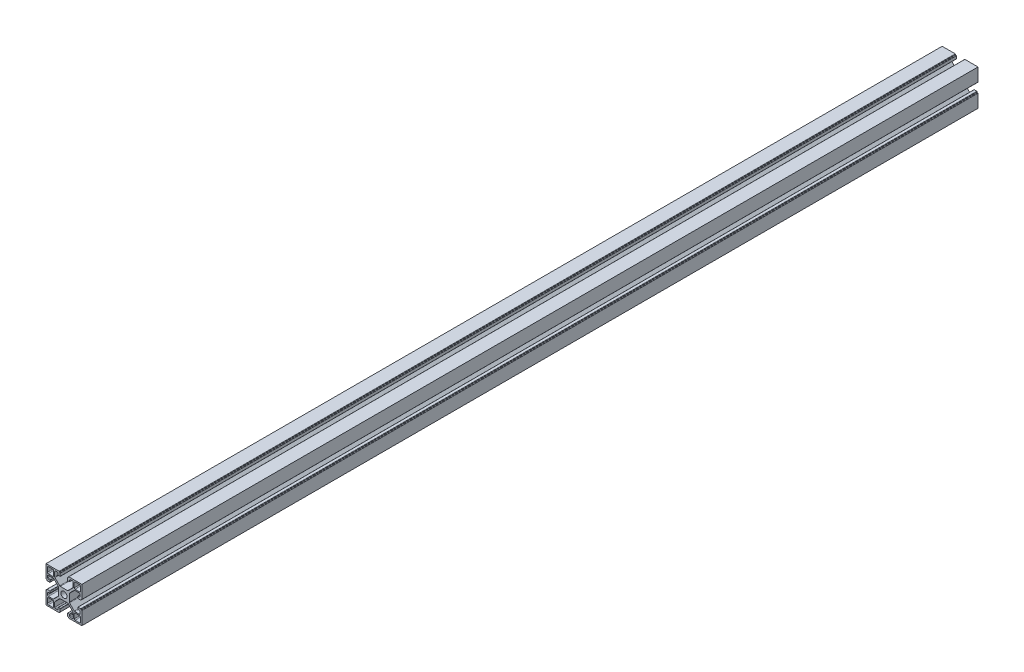
from build123d import *

# Parameters (mm, degrees)
SKETCH_1_R      = 3.4
EXTRUDE_1_DEPTH = 1000


with BuildPart() as part:
    # Эскиз1 → Бобышка-Вытянуть1 (new body)
    with BuildSketch(Plane.XY):
        with BuildLine():
            Line((-20, 20), (-20, 10.25))
            Line((-20, 10.25), (-20, 5.4))
            ThreePointArc((-20, 5.4), (-19.912132034, 5.187867966), (-19.7, 5.1))
            Line((-19.7, 5.1), (-19.3, 5.1))
            ThreePointArc((-19.3, 5.1), (-19.087867966, 5.012132034), (-19, 4.8))
            Line((-19, 4.8), (-19, 4.4))
            ThreePointArc((-19, 4.4), (-18.912132034, 4.187867966), (-18.7, 4.1))
            Line((-18.7, 4.1), (-15.8, 4.1))
            ThreePointArc((-15.8, 4.1), (-15.587867966, 4.187867966), (-15.5, 4.4))
            Line((-15.5, 4.4), (-15.5, 6.1))
            ThreePointArc((-15.5, 6.1), (-15.587867966, 6.312132034), (-15.8, 6.4))
            Line((-15.8, 6.4), (-17.2, 6.4))
            ThreePointArc((-17.2, 6.4), (-17.907106781, 6.692893219), (-18.2, 7.4))
            Line((-18.2, 7.4), (-18.2, 9.25))
            ThreePointArc((-18.2, 9.25), (-17.907106781, 9.957106781), (-17.2, 10.25))
            Line((-17.2, 10.25), (-12.164213562, 10.25))
            ThreePointArc((-12.164213562, 10.25), (-11.78153013, 10.173879533), (-11.457106781, 9.957106781))
            Line((-11.457106781, 9.957106781), (-6.292893219, 4.792893219))
            ThreePointArc((-6.292893219, 4.792893219), (-6.076120467, 4.46846987), (-6, 4.085786438))
            Line((-6, 4.085786438), (-6, -4.085786438))
            ThreePointArc((-6, -4.085786438), (-6.076120467, -4.46846987), (-6.292893219, -4.792893219))
            Line((-6.292893219, -4.792893219), (-11.457106781, -9.957106781))
            ThreePointArc((-11.457106781, -9.957106781), (-11.78153013, -10.173879533), (-12.164213562, -10.25))
            Line((-12.164213562, -10.25), (-17.2, -10.25))
            ThreePointArc((-17.2, -10.25), (-17.907106781, -9.957106781), (-18.2, -9.25))
            Line((-18.2, -9.25), (-18.2, -7.4))
            ThreePointArc((-18.2, -7.4), (-17.907106781, -6.692893219), (-17.2, -6.4))
            Line((-17.2, -6.4), (-15.8, -6.4))
            ThreePointArc((-15.8, -6.4), (-15.587867966, -6.312132034), (-15.5, -6.1))
            Line((-15.5, -6.1), (-15.5, -4.4))
            ThreePointArc((-15.5, -4.4), (-15.587867966, -4.187867966), (-15.8, -4.1))
            Line((-15.8, -4.1), (-18.7, -4.1))
            ThreePointArc((-18.7, -4.1), (-18.912132034, -4.187867966), (-19, -4.4))
            Line((-19, -4.4), (-19, -4.8))
            ThreePointArc((-19, -4.8), (-19.087867966, -5.012132034), (-19.3, -5.1))
            Line((-19.3, -5.1), (-19.7, -5.1))
            ThreePointArc((-19.7, -5.1), (-19.912132034, -5.187867966), (-20, -5.4))
            Line((-20, -5.4), (-20, -10.25))
            Line((-20, -10.25), (-20, -20))
            Line((-20, -20), (-10.25, -20))
            Line((-10.25, -20), (-5.4, -20))
            ThreePointArc((-5.4, -20), (-5.187867966, -19.912132034), (-5.1, -19.7))
            Line((-5.1, -19.7), (-5.1, -19.3))
            ThreePointArc((-5.1, -19.3), (-5.012132034, -19.087867966), (-4.8, -19))
            Line((-4.8, -19), (-4.4, -19))
            ThreePointArc((-4.4, -19), (-4.187867966, -18.912132034), (-4.1, -18.7))
            Line((-4.1, -18.7), (-4.1, -15.8))
            ThreePointArc((-4.1, -15.8), (-4.187867966, -15.587867966), (-4.4, -15.5))
            Line((-4.4, -15.5), (-6.1, -15.5))
            ThreePointArc((-6.1, -15.5), (-6.312132034, -15.587867966), (-6.4, -15.8))
            Line((-6.4, -15.8), (-6.4, -17.2))
            ThreePointArc((-6.4, -17.2), (-6.692893219, -17.907106781), (-7.4, -18.2))
            Line((-7.4, -18.2), (-9.25, -18.2))
            ThreePointArc((-9.25, -18.2), (-9.957106781, -17.907106781), (-10.25, -17.2))
            Line((-10.25, -17.2), (-10.25, -12.164213562))
            ThreePointArc((-10.25, -12.164213562), (-10.173879533, -11.78153013), (-9.957106781, -11.457106781))
            Line((-9.957106781, -11.457106781), (-4.792893219, -6.292893219))
            ThreePointArc((-4.792893219, -6.292893219), (-4.46846987, -6.076120467), (-4.085786438, -6))
            Line((-4.085786438, -6), (4.085786438, -6))
            ThreePointArc((4.085786438, -6), (4.46846987, -6.076120467), (4.792893219, -6.292893219))
            Line((4.792893219, -6.292893219), (9.957106781, -11.457106781))
            ThreePointArc((9.957106781, -11.457106781), (10.173879533, -11.78153013), (10.25, -12.164213562))
            Line((10.25, -12.164213562), (10.25, -17.2))
            ThreePointArc((10.25, -17.2), (9.957106781, -17.907106781), (9.25, -18.2))
            Line((9.25, -18.2), (7.4, -18.2))
            ThreePointArc((7.4, -18.2), (6.692893219, -17.907106781), (6.4, -17.2))
            Line((6.4, -17.2), (6.4, -15.8))
            ThreePointArc((6.4, -15.8), (6.312132034, -15.587867966), (6.1, -15.5))
            Line((6.1, -15.5), (4.4, -15.5))
            ThreePointArc((4.4, -15.5), (4.187867966, -15.587867966), (4.1, -15.8))
            Line((4.1, -15.8), (4.1, -18.7))
            ThreePointArc((4.1, -18.7), (4.187867966, -18.912132034), (4.4, -19))
            Line((4.4, -19), (4.8, -19))
            ThreePointArc((4.8, -19), (5.012132034, -19.087867966), (5.1, -19.3))
            Line((5.1, -19.3), (5.1, -19.7))
            ThreePointArc((5.1, -19.7), (5.187867966, -19.912132034), (5.4, -20))
            Line((5.4, -20), (10.25, -20))
            Line((10.25, -20), (20, -20))
            Line((20, -20), (20, -10.25))
            Line((20, -10.25), (20, -5.4))
            ThreePointArc((20, -5.4), (19.912132034, -5.187867966), (19.7, -5.1))
            Line((19.7, -5.1), (19.3, -5.1))
            ThreePointArc((19.3, -5.1), (19.087867966, -5.012132034), (19, -4.8))
            Line((19, -4.8), (19, -4.4))
            ThreePointArc((19, -4.4), (18.912132034, -4.187867966), (18.7, -4.1))
            Line((18.7, -4.1), (15.8, -4.1))
            ThreePointArc((15.8, -4.1), (15.587867966, -4.187867966), (15.5, -4.4))
            Line((15.5, -4.4), (15.5, -6.1))
            ThreePointArc((15.5, -6.1), (15.587867966, -6.312132034), (15.8, -6.4))
            Line((15.8, -6.4), (17.2, -6.4))
            ThreePointArc((17.2, -6.4), (17.907106781, -6.692893219), (18.2, -7.4))
            Line((18.2, -7.4), (18.2, -9.25))
            ThreePointArc((18.2, -9.25), (17.907106781, -9.957106781), (17.2, -10.25))
            Line((17.2, -10.25), (12.164213562, -10.25))
            ThreePointArc((12.164213562, -10.25), (11.78153013, -10.173879533), (11.457106781, -9.957106781))
            Line((11.457106781, -9.957106781), (6.292893219, -4.792893219))
            ThreePointArc((6.292893219, -4.792893219), (6.076120467, -4.46846987), (6, -4.085786438))
            Line((6, -4.085786438), (6, 4.085786438))
            ThreePointArc((6, 4.085786438), (6.076120467, 4.46846987), (6.292893219, 4.792893219))
            Line((6.292893219, 4.792893219), (11.457106781, 9.957106781))
            ThreePointArc((11.457106781, 9.957106781), (11.78153013, 10.173879533), (12.164213562, 10.25))
            Line((12.164213562, 10.25), (17.2, 10.25))
            ThreePointArc((17.2, 10.25), (17.907106781, 9.957106781), (18.2, 9.25))
            Line((18.2, 9.25), (18.2, 7.4))
            ThreePointArc((18.2, 7.4), (17.907106781, 6.692893219), (17.2, 6.4))
            Line((17.2, 6.4), (15.8, 6.4))
            ThreePointArc((15.8, 6.4), (15.587867966, 6.312132034), (15.5, 6.1))
            Line((15.5, 6.1), (15.5, 4.4))
            ThreePointArc((15.5, 4.4), (15.587867966, 4.187867966), (15.8, 4.1))
            Line((15.8, 4.1), (18.7, 4.1))
            ThreePointArc((18.7, 4.1), (18.912132034, 4.187867966), (19, 4.4))
            Line((19, 4.4), (19, 4.8))
            ThreePointArc((19, 4.8), (19.087867966, 5.012132034), (19.3, 5.1))
            Line((19.3, 5.1), (19.7, 5.1))
            ThreePointArc((19.7, 5.1), (19.912132034, 5.187867966), (20, 5.4))
            Line((20, 5.4), (20, 10.25))
            Line((20, 10.25), (20, 20))
            Line((20, 20), (10.25, 20))
            Line((10.25, 20), (5.4, 20))
            ThreePointArc((5.4, 20), (5.187867966, 19.912132034), (5.1, 19.7))
            Line((5.1, 19.7), (5.1, 19.3))
            ThreePointArc((5.1, 19.3), (5.012132034, 19.087867966), (4.8, 19))
            Line((4.8, 19), (4.4, 19))
            ThreePointArc((4.4, 19), (4.187867966, 18.912132034), (4.1, 18.7))
            Line((4.1, 18.7), (4.1, 15.8))
            ThreePointArc((4.1, 15.8), (4.187867966, 15.587867966), (4.4, 15.5))
            Line((4.4, 15.5), (6.1, 15.5))
            ThreePointArc((6.1, 15.5), (6.312132034, 15.587867966), (6.4, 15.8))
            Line((6.4, 15.8), (6.4, 17.2))
            ThreePointArc((6.4, 17.2), (6.692893219, 17.907106781), (7.4, 18.2))
            Line((7.4, 18.2), (9.25, 18.2))
            ThreePointArc((9.25, 18.2), (9.957106781, 17.907106781), (10.25, 17.2))
            Line((10.25, 17.2), (10.25, 12.164213562))
            ThreePointArc((10.25, 12.164213562), (10.173879533, 11.78153013), (9.957106781, 11.457106781))
            Line((9.957106781, 11.457106781), (4.792893219, 6.292893219))
            ThreePointArc((4.792893219, 6.292893219), (4.46846987, 6.076120467), (4.085786438, 6))
            Line((4.085786438, 6), (-4.085786438, 6))
            ThreePointArc((-4.085786438, 6), (-4.46846987, 6.076120467), (-4.792893219, 6.292893219))
            Line((-4.792893219, 6.292893219), (-9.957106781, 11.457106781))
            ThreePointArc((-9.957106781, 11.457106781), (-10.173879533, 11.78153013), (-10.25, 12.164213562))
            Line((-10.25, 12.164213562), (-10.25, 17.2))
            ThreePointArc((-10.25, 17.2), (-9.957106781, 17.907106781), (-9.25, 18.2))
            Line((-9.25, 18.2), (-7.4, 18.2))
            ThreePointArc((-7.4, 18.2), (-6.692893219, 17.907106781), (-6.4, 17.2))
            Line((-6.4, 17.2), (-6.4, 15.8))
            ThreePointArc((-6.4, 15.8), (-6.312132034, 15.587867966), (-6.1, 15.5))
            Line((-6.1, 15.5), (-4.4, 15.5))
            ThreePointArc((-4.4, 15.5), (-4.187867966, 15.587867966), (-4.1, 15.8))
            Line((-4.1, 15.8), (-4.1, 18.7))
            ThreePointArc((-4.1, 18.7), (-4.187867966, 18.912132034), (-4.4, 19))
            Line((-4.4, 19), (-4.8, 19))
            ThreePointArc((-4.8, 19), (-5.012132034, 19.087867966), (-5.1, 19.3))
            Line((-5.1, 19.3), (-5.1, 19.7))
            ThreePointArc((-5.1, 19.7), (-5.187867966, 19.912132034), (-5.4, 20))
            Line((-5.4, 20), (-10.25, 20))
            Line((-10.25, 20), (-20, 20))
        make_face()
        with BuildLine():
            ThreePointArc((-12.5, -11.5), (-11.792893219, -11.792893219), (-11.5, -12.5))
            Line((-11.5, -12.5), (-11.5, -17.5))
            ThreePointArc((-11.5, -17.5), (-11.792893219, -18.207106781), (-12.5, -18.5))
            Line((-12.5, -18.5), (-17.5, -18.5))
            ThreePointArc((-17.5, -18.5), (-18.207106781, -18.207106781), (-18.5, -17.5))
            Line((-18.5, -17.5), (-18.5, -12.5))
            ThreePointArc((-18.5, -12.5), (-18.207106781, -11.792893219), (-17.5, -11.5))
            Line((-17.5, -11.5), (-12.5, -11.5))
        make_face(mode=Mode.SUBTRACT)
        with BuildLine():
            ThreePointArc((11.5, -12.5), (11.792893219, -11.792893219), (12.5, -11.5))
            Line((12.5, -11.5), (17.5, -11.5))
            ThreePointArc((17.5, -11.5), (18.207106781, -11.792893219), (18.5, -12.5))
            Line((18.5, -12.5), (18.5, -17.5))
            ThreePointArc((18.5, -17.5), (18.207106781, -18.207106781), (17.5, -18.5))
            Line((17.5, -18.5), (12.5, -18.5))
            ThreePointArc((12.5, -18.5), (11.792893219, -18.207106781), (11.5, -17.5))
            Line((11.5, -17.5), (11.5, -12.5))
        make_face(mode=Mode.SUBTRACT)
        Circle(SKETCH_1_R, mode=Mode.SUBTRACT)
        with BuildLine():
            ThreePointArc((-11.5, 12.5), (-11.792893219, 11.792893219), (-12.5, 11.5))
            Line((-12.5, 11.5), (-17.5, 11.5))
            ThreePointArc((-17.5, 11.5), (-18.207106781, 11.792893219), (-18.5, 12.5))
            Line((-18.5, 12.5), (-18.5, 17.5))
            ThreePointArc((-18.5, 17.5), (-18.207106781, 18.207106781), (-17.5, 18.5))
            Line((-17.5, 18.5), (-12.5, 18.5))
            ThreePointArc((-12.5, 18.5), (-11.792893219, 18.207106781), (-11.5, 17.5))
            Line((-11.5, 17.5), (-11.5, 12.5))
        make_face(mode=Mode.SUBTRACT)
        with BuildLine():
            ThreePointArc((12.5, 11.5), (11.792893219, 11.792893219), (11.5, 12.5))
            Line((11.5, 12.5), (11.5, 17.5))
            ThreePointArc((11.5, 17.5), (11.792893219, 18.207106781), (12.5, 18.5))
            Line((12.5, 18.5), (17.5, 18.5))
            ThreePointArc((17.5, 18.5), (18.207106781, 18.207106781), (18.5, 17.5))
            Line((18.5, 17.5), (18.5, 12.5))
            ThreePointArc((18.5, 12.5), (18.207106781, 11.792893219), (17.5, 11.5))
            Line((17.5, 11.5), (12.5, 11.5))
        make_face(mode=Mode.SUBTRACT)
    extrude(amount=EXTRUDE_1_DEPTH)


solid = part.part
